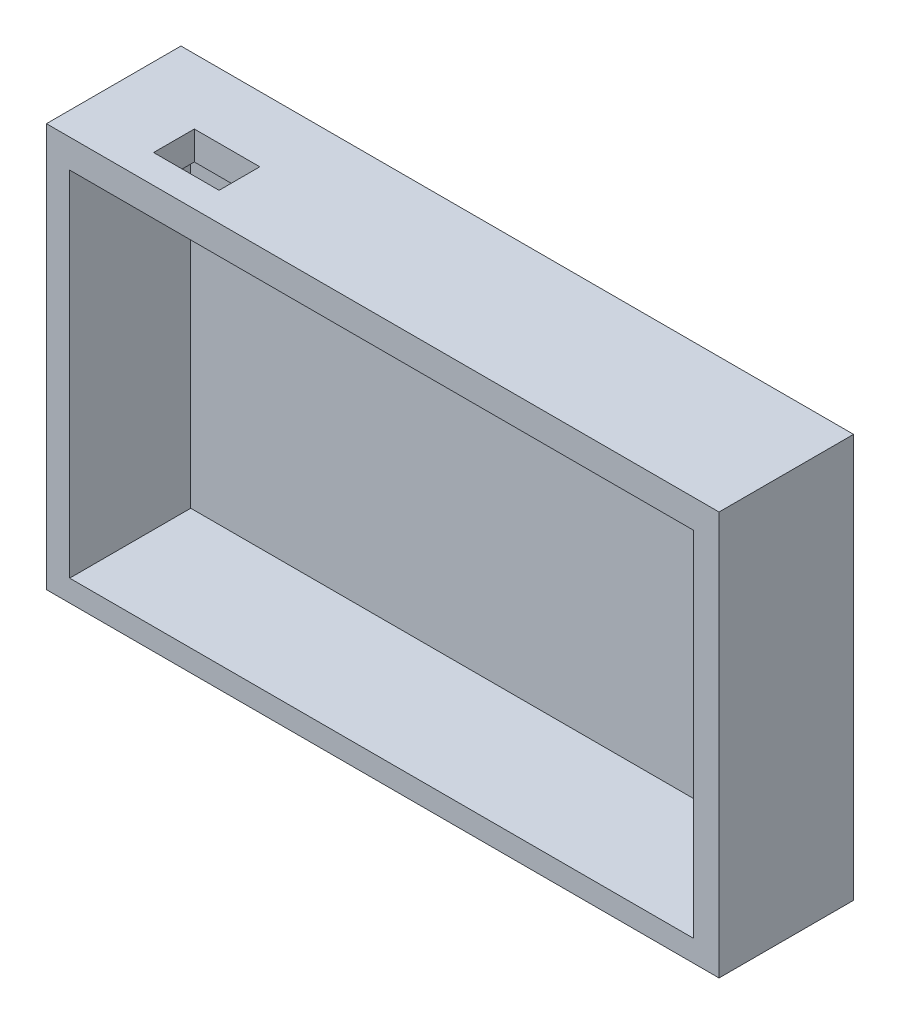
from build123d import *

# Parameters (mm, degrees)
SKETCH1_W           = 100
SKETCH1_H           = 60
BOSS_EXTRUDE2_DEPTH = 20
SKETCH3_W           = 92.779208915
SKETCH3_H           = 52.543855216
CUT_EXTRUDE2_DEPTH  = 18
SKETCH5_W           = 9.735170028
SKETCH5_H           = 6.058306193
CUT_EXTRUDE3_DEPTH  = 10


with BuildPart() as part:
    # Sketch1 → Boss-Extrude2 (new body)
    with BuildSketch(Plane.XY):
        with Locations((5.789473684, -6.842105263)):
            Rectangle(SKETCH1_W, SKETCH1_H)
    extrude(amount=BOSS_EXTRUDE2_DEPTH)

    # Sketch3 → Cut-Extrude2 (cut)
    with BuildSketch(Plane.XY.offset(20)):
        with Locations((5.634324506, -7.359269192)):
            Rectangle(SKETCH3_W, SKETCH3_H)
    extrude(amount=-CUT_EXTRUDE2_DEPTH, mode=Mode.SUBTRACT)

    # Sketch5 → Cut-Extrude3 (cut)
    with BuildSketch(Plane(origin=(0, 23.157894737, 0), x_dir=(1, 0, 0), z_dir=(0, 1, 0))):
        with Locations((-27.662514426, -12.720024884)):
            Rectangle(SKETCH5_W, SKETCH5_H)
    extrude(amount=-CUT_EXTRUDE3_DEPTH, mode=Mode.SUBTRACT)


solid = part.part
